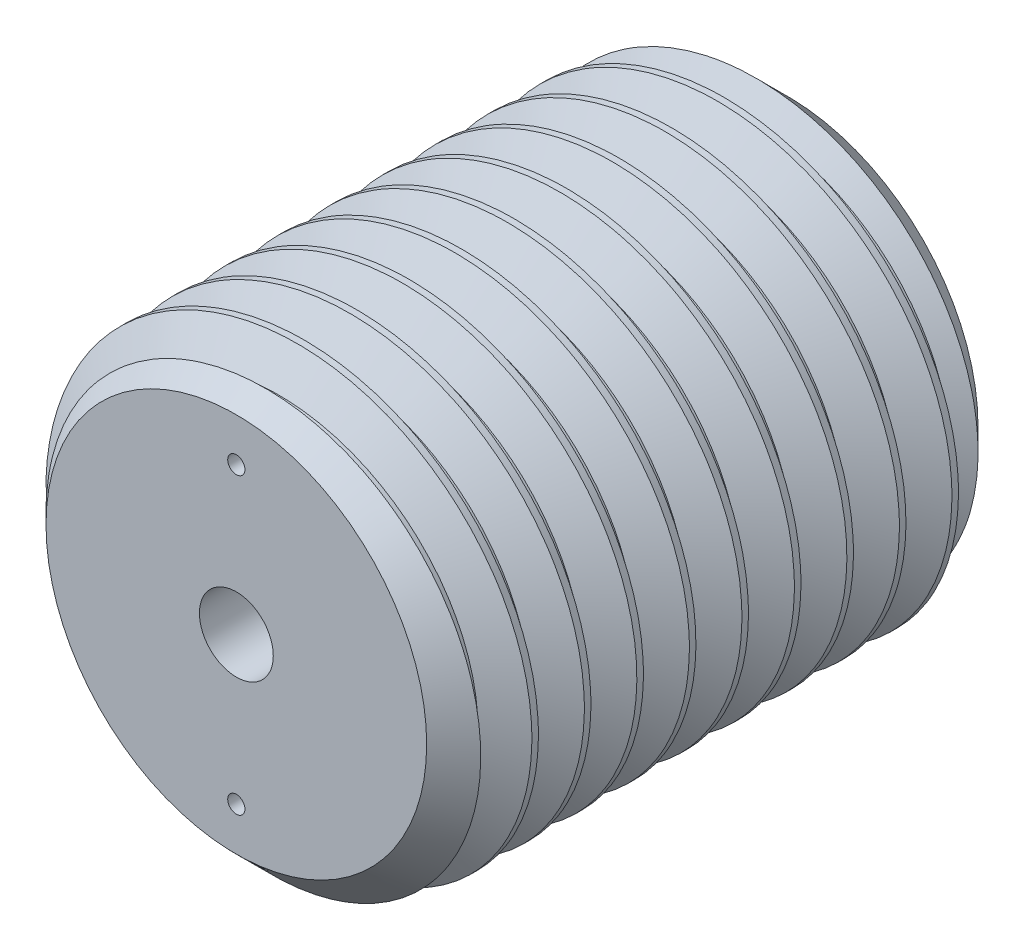
from build123d import *

# Parameters (mm, degrees)
SKETCH1_R                           = 15.875
BOSS_EXTRUDE1_DEPTH                 = 19.05
CHAMFER1_SIZE                       = 2.721428571
CUT_SWEEP1_PITCH                    = 3.628571429
CUT_SWEEP1_HEIGHT                   = 41.728571429
CUT_SWEEP1_RADIUS                   = 15.875
CUT_SWEEP1_START_ANGLE              = 90
F_1_4_20_TAPPED_HOLE1_D             = 5.1054
F_1_4_20_TAPPED_HOLE1_DEPTH         = 11.938
F_1_4_20_TAPPED_HOLE1_TIP           = 1.533816902
F_3_64_0_04688_DIAMETER_HOLE1_D     = 1.190752
F_3_64_0_04688_DIAMETER_HOLE1_DEPTH = 2.54
F_3_64_0_04688_DIAMETER_HOLE1_TIP   = 0.357737992


with BuildPart() as part:
    # Sketch1 → Boss-Extrude1 (new, symmetric)
    with BuildSketch(Plane.XY):
        with Locations(Location((0, 0, 0), (0, 0, 180))):
            Circle(SKETCH1_R)
    extrude(amount=BOSS_EXTRUDE1_DEPTH, both=True)

    # Chamfer1
    chamfer1_edges = [part.edges().sort_by_distance(p)[0] for p in [
        (15.875, 0, -19.05),
        (15.875, 0, 19.05),
    ]]
    chamfer(chamfer1_edges, length=CHAMFER1_SIZE)

    # Cut-Sweep1: sweep along a helix
    with BuildLine() as cut_sweep1_path:
        add(Helix(CUT_SWEEP1_PITCH, CUT_SWEEP1_HEIGHT, CUT_SWEEP1_RADIUS, center=(0, 0, 19.05), direction=(0, 0, -1), mode=Mode.PRIVATE).rotate(Axis((0, 0, 19.05), (0, 0, -1)), CUT_SWEEP1_START_ANGLE))
    # Sketch5 → Cut-Sweep1 (sweep, cut)
    with BuildSketch(Plane(origin=(0, 0, 0), x_dir=(0, 0, -1), z_dir=(1, 0, 0))):
        Polygon((-20.864285714, 13.518173723), (-20.410714286, 13.518173723), (-18.903353032, 16.129), (-22.371646968, 16.129), align=None)
    sweep(path=cut_sweep1_path.line, is_frenet=True, mode=Mode.SUBTRACT)

    # 1/4-20 Tapped Hole1
    with Locations(Plane.XY.offset(19.05)):
        with Locations((0, 0)):
            Hole(F_1_4_20_TAPPED_HOLE1_D / 2, depth=F_1_4_20_TAPPED_HOLE1_DEPTH)
            with Locations((0, 0, -(F_1_4_20_TAPPED_HOLE1_DEPTH + F_1_4_20_TAPPED_HOLE1_TIP / 2))):  # 118° drill point
                Cone(0, F_1_4_20_TAPPED_HOLE1_D / 2, F_1_4_20_TAPPED_HOLE1_TIP, mode=Mode.SUBTRACT)

    # 3/64 (0.04688) Diameter Hole1
    with Locations(Plane.XY.offset(19.05)):
        with Locations((0, 10.16), (0, -10.16)):
            Hole(F_3_64_0_04688_DIAMETER_HOLE1_D / 2, depth=F_3_64_0_04688_DIAMETER_HOLE1_DEPTH)
            with Locations((0, 0, -(F_3_64_0_04688_DIAMETER_HOLE1_DEPTH + F_3_64_0_04688_DIAMETER_HOLE1_TIP / 2))):  # 118° drill point
                Cone(0, F_3_64_0_04688_DIAMETER_HOLE1_D / 2, F_3_64_0_04688_DIAMETER_HOLE1_TIP, mode=Mode.SUBTRACT)


solid = part.part
